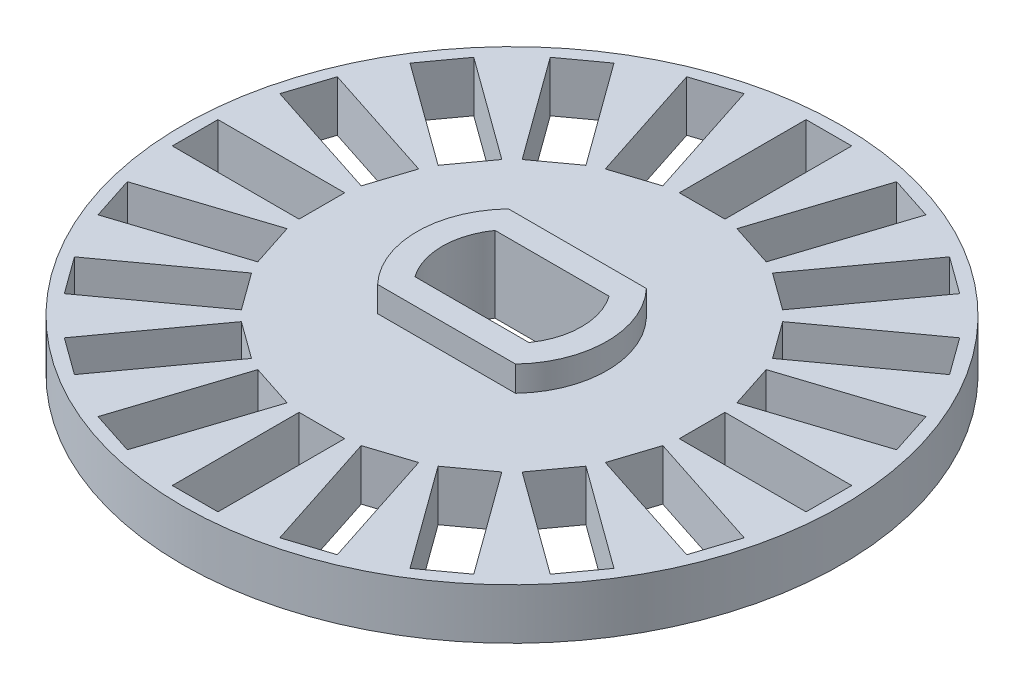
from build123d import *

# Parameters (mm, degrees)
SKETCH1_R           = 13
SKETCH1_W           = 1.8
SKETCH1_H           = 5
SKETCH1_W_2         = 5
SKETCH1_H_2         = 1.8
BOSS_EXTRUDE1_DEPTH = 2
BOSS_EXTRUDE2_DEPTH = 1


with BuildPart() as part:
    # Sketch1 → Boss-Extrude1 (new body)
    with BuildSketch(Plane(origin=(0, 0, 0), x_dir=(1, 0, 0), z_dir=(0, 1, 0))):
        Circle(SKETCH1_R)
        with BuildLine():
            Line((-2.25, 1.58113883), (2.25, 1.58113883))
            ThreePointArc((2.25, 1.58113883), (2.75, 0), (2.25, -1.58113883))
            Line((2.25, -1.58113883), (-2.25, -1.58113883))
            ThreePointArc((-2.25, -1.58113883), (-2.75, 0), (-2.25, 1.58113883))
        make_face(mode=Mode.SUBTRACT)
        Polygon((1.461676593, 7.411039167), (3.006761565, 12.166321749), (4.718663294, 11.610091159), (3.173578322, 6.854808577), align=None, mode=Mode.SUBTRACT)
        with Locations((0, 10)):
            Rectangle(SKETCH1_W, SKETCH1_H, mode=Mode.SUBTRACT)
        Polygon((3.680274097, 6.596634185), (6.619200359, 10.641719157), (8.075430949, 9.583705703), (5.136504687, 5.538620731), align=None, mode=Mode.SUBTRACT)
        Polygon((5.538620731, 5.136504687), (9.583705703, 8.075430949), (10.641719157, 6.619200359), (6.596634185, 3.680274097), align=None, mode=Mode.SUBTRACT)
        Polygon((6.854808577, 3.173578322), (11.610091159, 4.718663294), (12.166321749, 3.006761565), (7.411039167, 1.461676593), align=None, mode=Mode.SUBTRACT)
        with Locations((10, 0)):
            Rectangle(SKETCH1_W_2, SKETCH1_H_2, mode=Mode.SUBTRACT)
        Polygon((7.411039167, -1.461676593), (12.166321749, -3.006761565), (11.610091159, -4.718663294), (6.854808577, -3.173578322), align=None, mode=Mode.SUBTRACT)
        Polygon((6.596634185, -3.680274097), (10.641719157, -6.619200359), (9.583705703, -8.075430949), (5.538620731, -5.136504687), align=None, mode=Mode.SUBTRACT)
        Polygon((5.136504687, -5.538620731), (8.075430949, -9.583705703), (6.619200359, -10.641719157), (3.680274097, -6.596634185), align=None, mode=Mode.SUBTRACT)
        Polygon((3.173578322, -6.854808577), (4.718663294, -11.610091159), (3.006761565, -12.166321749), (1.461676593, -7.411039167), align=None, mode=Mode.SUBTRACT)
        with Locations((0, -10)):
            Rectangle(SKETCH1_W, SKETCH1_H, mode=Mode.SUBTRACT)
        Polygon((-1.461676593, -7.411039167), (-3.006761565, -12.166321749), (-4.718663294, -11.610091159), (-3.173578322, -6.854808577), align=None, mode=Mode.SUBTRACT)
        Polygon((-3.680274097, -6.596634185), (-6.619200359, -10.641719157), (-8.075430949, -9.583705703), (-5.136504687, -5.538620731), align=None, mode=Mode.SUBTRACT)
        Polygon((-5.538620731, -5.136504687), (-9.583705703, -8.075430949), (-10.641719157, -6.619200359), (-6.596634185, -3.680274097), align=None, mode=Mode.SUBTRACT)
        Polygon((-6.854808577, -3.173578322), (-11.610091159, -4.718663294), (-12.166321749, -3.006761565), (-7.411039167, -1.461676593), align=None, mode=Mode.SUBTRACT)
        with Locations((-10, 0)):
            Rectangle(SKETCH1_W_2, SKETCH1_H_2, mode=Mode.SUBTRACT)
        Polygon((-7.411039167, 1.461676593), (-12.166321749, 3.006761565), (-11.610091159, 4.718663294), (-6.854808577, 3.173578322), align=None, mode=Mode.SUBTRACT)
        Polygon((-6.596634185, 3.680274097), (-10.641719157, 6.619200359), (-9.583705703, 8.075430949), (-5.538620731, 5.136504687), align=None, mode=Mode.SUBTRACT)
        Polygon((-5.136504687, 5.538620731), (-8.075430949, 9.583705703), (-6.619200359, 10.641719157), (-3.680274097, 6.596634185), align=None, mode=Mode.SUBTRACT)
        Polygon((-3.173578322, 6.854808577), (-4.718663294, 11.610091159), (-3.006761565, 12.166321749), (-1.461676593, 7.411039167), align=None, mode=Mode.SUBTRACT)
    extrude(amount=BOSS_EXTRUDE1_DEPTH)

    # Sketch2 → Boss-Extrude2 (add)
    with BuildSketch(Plane(origin=(0, 2, 0), x_dir=(1, 0, 0), z_dir=(0, 1, 0))):
        with BuildLine():
            Line((-2.720334968, -2.58113883), (2.720334968, -2.58113883))
            ThreePointArc((2.720334968, -2.58113883), (3.75, 0), (2.720334968, 2.58113883))
            Line((2.720334968, 2.58113883), (-2.720334968, 2.58113883))
            ThreePointArc((-2.720334968, 2.58113883), (-3.75, 0), (-2.720334968, -2.58113883))
        make_face()
        with BuildLine():
            Line((-2.25, -1.58113883), (2.25, -1.58113883))
            ThreePointArc((2.25, -1.58113883), (2.75, 0), (2.25, 1.58113883))
            Line((2.25, 1.58113883), (-2.25, 1.58113883))
            ThreePointArc((-2.25, 1.58113883), (-2.75, 0), (-2.25, -1.58113883))
        make_face(mode=Mode.SUBTRACT)
    extrude(amount=BOSS_EXTRUDE2_DEPTH)


solid = part.part
